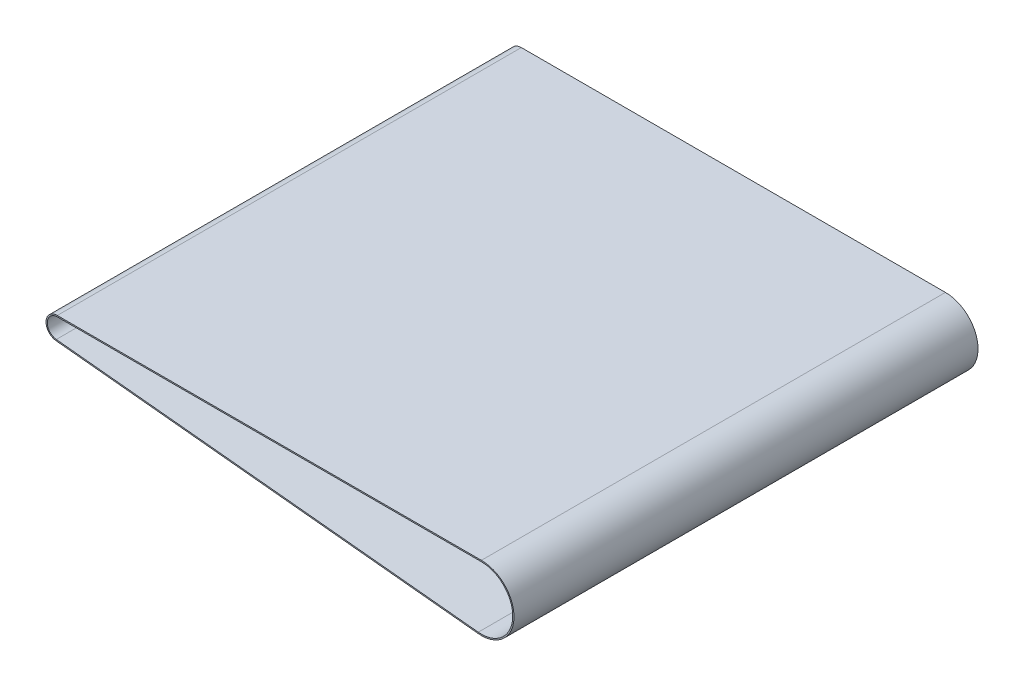
from build123d import *

# Parameters (mm, degrees)
EXTRUDE_1_DEPTH = 370


with BuildPart() as part:
    # 草图1 → 凸台-拉伸1 (new body)
    with BuildSketch(Plane.XY):
        with BuildLine():
            Line((-24.246153846, 1), (313.926819645, 1))
            ThreePointArc((313.926819645, 1), (339.894029659, -26.305375074), (311.319362054, -50.868922763))
            Line((311.319362054, -50.868922763), (-25.14873532, -16.95462711))
            ThreePointArc((-25.14873532, -16.95462711), (-33.234803466, -7.548139398), (-24.246153846, 1))
        make_face()
        with BuildLine():
            Line((-24.246153846, 0), (313.926819645, 0))
            ThreePointArc((313.926819645, 0), (338.895290813, -26.25516834), (311.419648884, -49.873964195))
            Line((311.419648884, -49.873964195), (-25.04844849, -15.959668542))
            ThreePointArc((-25.04844849, -15.959668542), (-32.23606462, -7.598346131), (-24.246153846, 0))
        make_face(mode=Mode.SUBTRACT)
    extrude(amount=EXTRUDE_1_DEPTH)


solid = part.part
